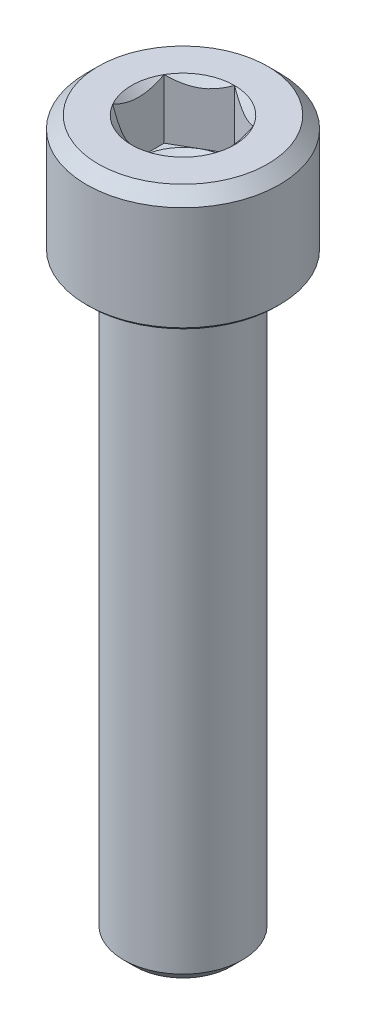
from build123d import *

# Parameters (mm, degrees)
CUT_EXTRUDE1_DEPTH = 4


with BuildPart() as part:
    # Sketch1 → Revolve1 (revolve)
    with BuildSketch(Plane.XY):
        Polygon((0, 2.267949192), (3, 4), (3, 7.535898385), (3.464101615, 8), (5.7, 8), (6.5, 7.2), (6.5, 0.2), (6.3, 0), (4.05, 0), (4, -1.02), (4, -39.233), (3.233, -40), (0, -40), align=None)
    revolve(axis=Axis((0, -40, 0), (0, 1, 0)))

    # Sketch2 → Cut-Extrude1 (cut)
    with BuildSketch(Plane(origin=(0, 8, 0), x_dir=(1, 0, 0), z_dir=(0, 1, 0))):
        Polygon((-3, -1.732050808), (0, -3.464101615), (3, -1.732050808), (3, 1.732050808), (0, 3.464101615), (-3, 1.732050808), align=None)
    extrude(amount=-CUT_EXTRUDE1_DEPTH, mode=Mode.SUBTRACT)


solid = part.part
